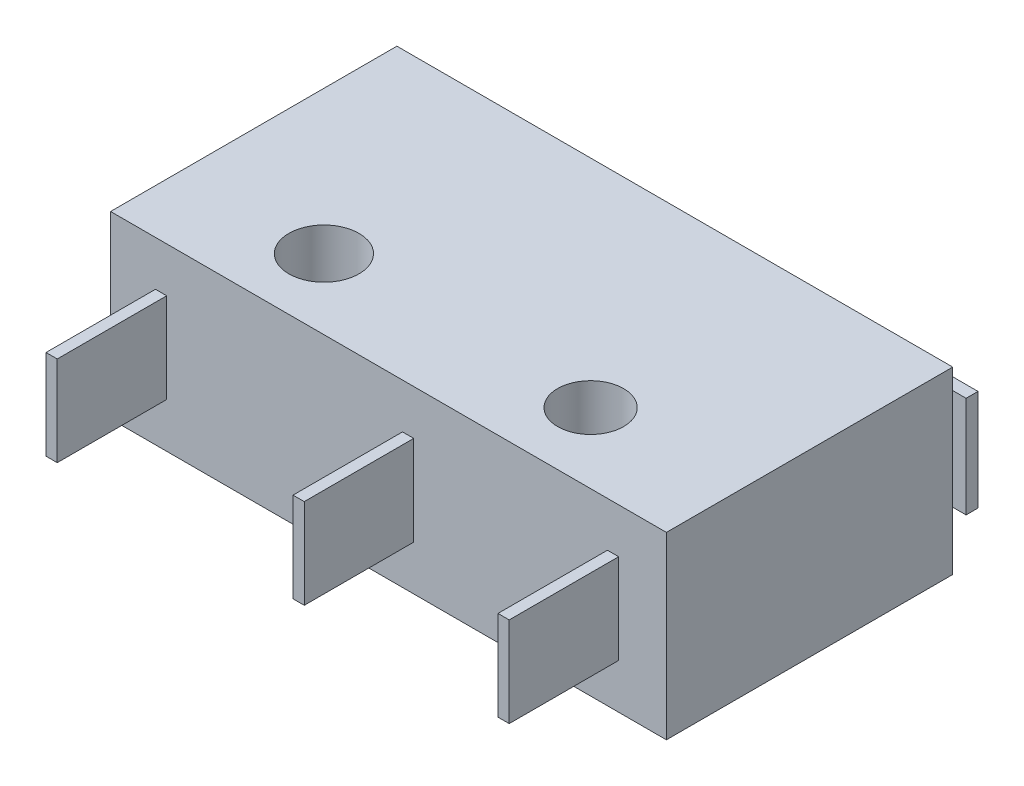
from build123d import *

# Parameters (mm, degrees)
SKETCH1_W               = 19.8
SKETCH1_H               = 10.2
BOSS_EXTRUDE1_DEPTH     = 3.2
SKETCH2_R               = 1.25
SKETCH2_R_2             = 1.175
CUT_EXTRUDE1_DEPTH      = 4.2
CUT_EXTRUDE1_DEPTH_BACK = 4.2
BOSS_EXTRUDE2_DEPTH     = 1.8
SKETCH4_W               = 0.4
SKETCH4_H               = 3.2
BOSS_EXTRUDE3_DEPTH     = 3.9
LPATTERN1_COUNT         = 2
LPATTERN1_PITCH         = 8.8
LPATTERN2_COUNT         = 2
LPATTERN2_PITCH         = 16.1
SKETCH5_R               = 0.507136528
BOSS_EXTRUDE4_DEPTH     = 1.7


with BuildPart() as part:
    # Sketch1 → Boss-Extrude1 (new body, symmetric)
    with BuildSketch(Plane(origin=(0, 0, 0), x_dir=(1, 0, 0), z_dir=(0, 1, 0))):
        Rectangle(SKETCH1_W, SKETCH1_H)
    extrude(amount=BOSS_EXTRUDE1_DEPTH, both=True)

    # Sketch2 → Cut-Extrude1 (cut, two sides)
    with BuildSketch(Plane(origin=(0, 0, 0), x_dir=(1, 0, 0), z_dir=(0, 1, 0))) as cut_extrude1_sk:
        with Locations((-4.8, -2.6)):
            Circle(SKETCH2_R)
        with Locations((4.7, -2.6)):
            Circle(SKETCH2_R_2)
    extrude(amount=CUT_EXTRUDE1_DEPTH, mode=Mode.SUBTRACT)
    extrude(cut_extrude1_sk.sketch, amount=-CUT_EXTRUDE1_DEPTH_BACK, mode=Mode.SUBTRACT)

    # Sketch3 → Boss-Extrude2 (add, symmetric)
    with BuildSketch(Plane(origin=(0, 0, 0), x_dir=(1, 0, 0), z_dir=(0, 1, 0))):
        Polygon((-7.306635191, 5.1), (-7.306635191, 6.2), (9.7, 6.2), (9.7, 5.775620591), (-6.694229351, 5.775620591), (-6.694229351, 5.1), align=None)
    extrude(amount=BOSS_EXTRUDE2_DEPTH, both=True)

    # Sketch4 → Boss-Extrude3 (add)
    with BuildSketch(Plane.XY.offset(5.1)):
        with Locations((-8.1, 0)):
            Rectangle(SKETCH4_W, SKETCH4_H)
    boss_extrude3 = extrude(amount=BOSS_EXTRUDE3_DEPTH)

    # LPattern1: Boss-Extrude3 ×2
    with Locations(*[(i * LPATTERN1_PITCH, 0, 0) for i in range(1, LPATTERN1_COUNT)]):
        add(boss_extrude3)

    # LPattern2: Boss-Extrude3 ×2
    with Locations(*[(i * LPATTERN2_PITCH, 0, 0) for i in range(1, LPATTERN2_COUNT)]):
        add(boss_extrude3)

    # Sketch5 → Boss-Extrude4 (add, symmetric)
    with BuildSketch(Plane(origin=(0, 0, 0), x_dir=(1, 0, 0), z_dir=(0, 1, 0))):
        with Locations((-3.307427246, 5.1)):
            Circle(SKETCH5_R)
    extrude(amount=BOSS_EXTRUDE4_DEPTH, both=True)


solid = part.part
